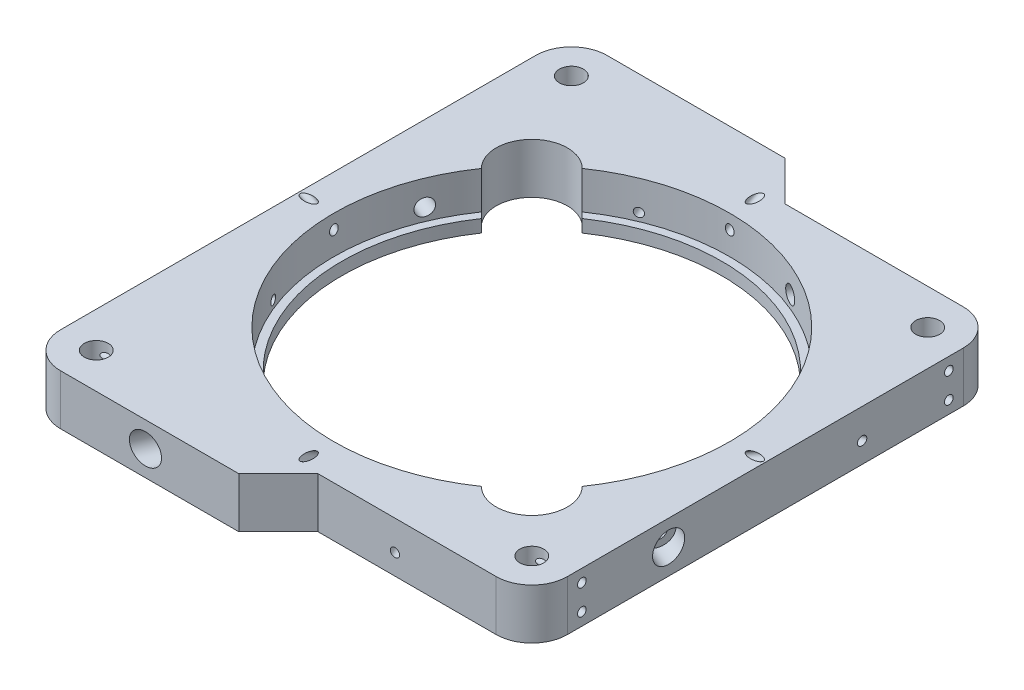
from build123d import *

# Parameters (mm, degrees)
SKETCH1_R                           = 3.025
BOSS_EXTRUDE1_DEPTH                 = 12.7
SKETCH2_R                           = 1.095
CUT_EXTRUDE1_DEPTH                  = 15
SKETCH5_R                           = 2.1
CUT_EXTRUDE2_DEPTH                  = 92.669460642
SKETCH6_R                           = 1.095
CUT_EXTRUDE3_DEPTH                  = 92.669460642
CUT_EXTRUDE4_REACH                  = 132.228
SKETCH7_R                           = 1.095
CUT_EXTRUDE4_DIRECTION_2_REACH      = 132.228
CUT_EXTRUDE4_DIRECTION_2_END_RADIUS = 50
CIRPATTERN1_COUNT                   = 4
CUT_EXTRUDE5_DEPTH                  = 92.669460717
CIRPATTERN2_COUNT                   = 2
CUT_EXTRUDE6_START                  = -156.002790717
SKETCH9_R                           = 3.75
CUT_EXTRUDE6_DEPTH                  = 97.669460717
CIRPATTERN6_COUNT                   = 4
SKETCH10_R                          = 1.095
CUT_EXTRUDE7_DEPTH                  = 15


with BuildPart() as part:
    # Sketch1 → Boss-Extrude1 (new body)
    with BuildSketch(Plane(origin=(0, 0, 0), x_dir=(1, 0, 0), z_dir=(0, 1, 0))):
        with BuildLine():
            Line((5, 59), (-5, 69))
            Line((-5, 69), (-50, 69))
            ThreePointArc((-50, 69), (-56.363961031, 66.363961031), (-59, 60))
            Line((-59, 60), (-59, -60))
            ThreePointArc((-59, -60), (-56.363961031, -66.363961031), (-50, -69))
            Line((-50, -69), (-5, -69))
            Line((-5, -69), (5, -59))
            Line((5, -59), (50, -59))
            ThreePointArc((50, -59), (56.363961031, -56.363961031), (59, -50))
            Line((59, -50), (59, 50))
            ThreePointArc((59, 50), (56.363961031, 56.363961031), (50, 59))
            Line((50, 59), (5, 59))
        make_face()
        with Locations(Location((50, 50, 0), (0, 0, 270))):
            Circle(SKETCH1_R, mode=Mode.SUBTRACT)
        with Locations(Location((50, -50, 0), (0, 0, 270))):
            Circle(SKETCH1_R, mode=Mode.SUBTRACT)
        with Locations(Location((-50, 60, 0), (0, 0, 270))):
            Circle(SKETCH1_R, mode=Mode.SUBTRACT)
        with Locations(Location((-50, -60, 0), (0, 0, 270))):
            Circle(SKETCH1_R, mode=Mode.SUBTRACT)
    extrude(amount=BOSS_EXTRUDE1_DEPTH)

    # Sketch2 → Cut-Extrude1 (cut)
    with BuildSketch(Plane(origin=(59, 0, 0), x_dir=(0, 0, -1), z_dir=(1, 0, 0))):
        with Locations((-46.35, 9.525)):
            Circle(SKETCH2_R)
        with Locations((-46.35, 3.175)):
            Circle(SKETCH2_R)
        with Locations((46.35, 9.525)):
            Circle(SKETCH2_R)
        with Locations((46.35, 3.175)):
            Circle(SKETCH2_R)
    extrude(amount=-CUT_EXTRUDE1_DEPTH, mode=Mode.SUBTRACT)

    # Sketch4 → Cut-Revolve1 (revolve, cut)
    with BuildSketch(Plane.XY):
        Polygon((0, 0), (0, 12.7), (50, 12.7), (50, 3.175), (48, 3.175), (48, 0), align=None)
    revolve(axis=Axis((0, 0, 0), (0, 1, 0)), mode=Mode.SUBTRACT)

    # Sketch5 → Cut-Extrude2 (cut, through all)
    with BuildSketch(Plane(origin=(0, 0, 0), x_dir=(0.9238795325112865, 0, 0.3826834323650906), z_dir=(-0.38268343236509056, 0, 0.9238795325112864))):
        with Locations((0, 6.35)):
            Circle(SKETCH5_R)
    cut_extrude2 = extrude(amount=-CUT_EXTRUDE2_DEPTH, mode=Mode.SUBTRACT)

    # Sketch6 → Cut-Extrude3 (cut, through all)
    with BuildSketch(Plane(origin=(0, 0, 0), x_dir=(0.3826834323650874, 0, 0.9238795325112878), z_dir=(-0.9238795325112878, 0, 0.3826834323650874))):
        with Locations((0, 5.175)):
            Circle(SKETCH6_R)
    cut_extrude3 = extrude(amount=-CUT_EXTRUDE3_DEPTH, mode=Mode.SUBTRACT)

    # Cut-Extrude4: up to this plane
    cut_extrude4_end = Plane(origin=(50, 12.7, 50), z_dir=(0, 1, 0))
    # Sketch7 → Cut-Extrude4 (cut, up to the surface)
    with BuildSketch(Plane(origin=(0, 25.547749412, 44.25), x_dir=(-1, 0, 0), z_dir=(0, -0.500000000000001, -0.866025403784438)), mode=Mode.PRIVATE) as cut_extrude4_sk1:
        with Locations(Location((0, -17.176477372, 0), (0, 0, 90))):
            Circle(SKETCH7_R)
    cut_extrude4_tool1 = split(extrude(cut_extrude4_sk1.sketch, amount=-CUT_EXTRUDE4_REACH, mode=Mode.PRIVATE), bisect_by=cut_extrude4_end, keep=Keep.BOTH, mode=Mode.PRIVATE)
    cut_extrude4 = cut_extrude4_tool1.solids().sort_by_distance((0, 10.672484, 52.838239))[0]
    add(cut_extrude4, mode=Mode.SUBTRACT)

    # Cut-Extrude4 direction 2: up to this cylinder (the profile starts outside it)
    cut_extrude4_direction_2_end = Plane(origin=(0, 10.672484, 0), z_dir=(0, -1, 0)) * Cylinder(CUT_EXTRUDE4_DIRECTION_2_END_RADIUS, 365.456, mode=Mode.PRIVATE)
    # Sketch7 → Cut-Extrude4 direction 2 (cut, up to the surface)
    with BuildSketch(Plane(origin=(0, 25.547749412, 44.25), x_dir=(-1, 0, 0), z_dir=(0, -0.500000000000001, -0.866025403784438)), mode=Mode.PRIVATE) as cut_extrude4_direction_2_sk1:
        with Locations(Location((0, -17.176477372, 0), (0, 0, 90))):
            Circle(SKETCH7_R)
    cut_extrude4_direction_2_tool1 = extrude(cut_extrude4_direction_2_sk1.sketch, amount=CUT_EXTRUDE4_DIRECTION_2_REACH, mode=Mode.PRIVATE) - cut_extrude4_direction_2_end
    cut_extrude4_direction_2 = cut_extrude4_direction_2_tool1.solids().sort_by_distance((0, 10.672484, 52.838239))[0]
    add(cut_extrude4_direction_2, mode=Mode.SUBTRACT)
    cut_extrude4 = cut_extrude4 + cut_extrude4_direction_2  # both directions under the feature's name, for the pattern or mirror that repeats it

    # CirPattern1: Cut-Extrude2, Cut-Extrude3, Cut-Extrude4 ×4 about axis
    cirpattern1_axis = Axis((0, 13.335, 0), (0, -1, 0))
    add([cut_extrude2.rotate(cirpattern1_axis, i * 360 / CIRPATTERN1_COUNT) for i in range(1, CIRPATTERN1_COUNT)], mode=Mode.SUBTRACT)
    add([cut_extrude3.rotate(cirpattern1_axis, i * 360 / CIRPATTERN1_COUNT) for i in range(1, CIRPATTERN1_COUNT)], mode=Mode.SUBTRACT)
    add([cut_extrude4.rotate(cirpattern1_axis, i * 360 / CIRPATTERN1_COUNT) for i in range(1, CIRPATTERN1_COUNT)], mode=Mode.SUBTRACT)

    # Sketch8 → Cut-Extrude5 (cut, through all)
    with BuildSketch(Plane(origin=(0, 12.7, 0), x_dir=(1, 0, 0), z_dir=(0, 1, 0))):
        with BuildLine():
            Line((-41.141827555, 28.413905494), (-39.703127187, 26.975205126))
            Line((-39.703127187, 26.975205126), (-26.975205126, 39.703127187))
            Line((-26.975205126, 39.703127187), (-28.413905494, 41.141827555))
            ThreePointArc((-28.413905494, 41.141827555), (-41.141827555, 41.141827555), (-41.141827555, 28.413905494))
        make_face()
    cut_extrude5 = extrude(amount=-CUT_EXTRUDE5_DEPTH, mode=Mode.SUBTRACT)

    # CirPattern2: Cut-Extrude5 ×2 about axis
    cirpattern2_axis = Axis((0, 0, 0), (0, 1, 0))
    for i in range(1, CIRPATTERN2_COUNT):
        add(cut_extrude5.rotate(cirpattern2_axis, i * 360 / CIRPATTERN2_COUNT), mode=Mode.SUBTRACT)

    # Sketch9 → Cut-Extrude6 (cut)
    with BuildSketch(Plane(origin=(0, 0, 0), x_dir=(0.9238795325112865, 0, 0.3826834323650906), z_dir=(-0.38268343236509056, 0, 0.9238795325112864)).offset(CUT_EXTRUDE6_START)):
        with Locations((0, 6.35)):
            Circle(SKETCH9_R)
    cut_extrude6 = extrude(amount=CUT_EXTRUDE6_DEPTH, mode=Mode.SUBTRACT)

    # CirPattern6: Cut-Extrude6 ×4 about axis
    cirpattern6_axis = Axis((0, 0, 0), (0, 1, 0))
    for i in range(1, CIRPATTERN6_COUNT):
        add(cut_extrude6.rotate(cirpattern6_axis, i * 360 / CIRPATTERN6_COUNT), mode=Mode.SUBTRACT)

    # Sketch10 → Cut-Extrude7 (cut)
    with BuildSketch(Plane.ZY.offset(59)):
        with Locations((56.35, 9.525)):
            Circle(SKETCH10_R)
        with Locations((56.35, 3.175)):
            Circle(SKETCH10_R)
        with Locations((-56.35, 9.525)):
            Circle(SKETCH10_R)
        with Locations((-56.35, 3.175)):
            Circle(SKETCH10_R)
    extrude(amount=-CUT_EXTRUDE7_DEPTH, mode=Mode.SUBTRACT)


solid = part.part
